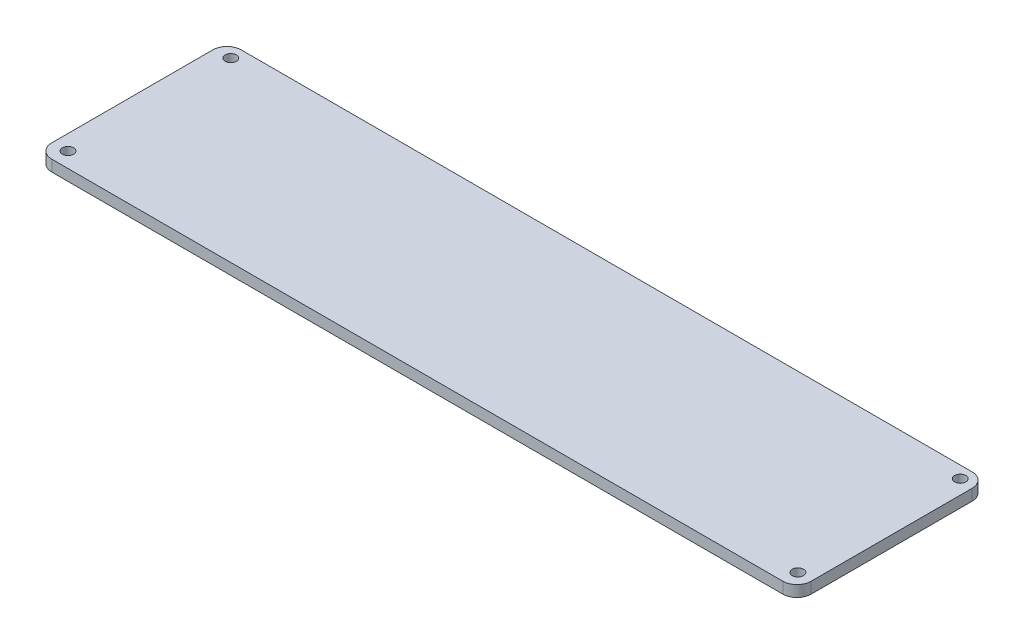
from build123d import *

# Parameters (mm, degrees)
SKETCH_1_W      = 203.2
SKETCH_1_H      = 50.673
SKETCH_1_R      = 1.5
EXTRUDE_1_DEPTH = 3
FILLET_1_R      = 3.8


with BuildPart() as part:
    # 草图1 → 凸台-拉伸1 (new body)
    with BuildSketch(Plane(origin=(0, 0, 0), x_dir=(1, 0, 0), z_dir=(0, 1, 0))):
        with Locations((-0.786381305, 0.982976631)):
            Rectangle(SKETCH_1_W, SKETCH_1_H)
        with Locations((97.003618695, -20.289523369)):
            Circle(SKETCH_1_R, mode=Mode.SUBTRACT)
        with Locations((97.003618695, 23.144476631)):
            Circle(SKETCH_1_R, mode=Mode.SUBTRACT)
        with Locations((-98.068381305, 23.017476631)):
            Circle(SKETCH_1_R, mode=Mode.SUBTRACT)
        with Locations((-98.322381305, -20.289523369)):
            Circle(SKETCH_1_R, mode=Mode.SUBTRACT)
    extrude(amount=EXTRUDE_1_DEPTH)

    # 圆角1
    fillet_1_edges = [part.edges().sort_by_distance(p)[0] for p in [
        (-102.386381305, 1.5, 24.353523369),
        (-102.386381305, 1.5, -26.319476631),
        (100.813618695, 1.5, -26.319476631),
        (100.813618695, 1.5, 24.353523369),
    ]]
    fillet(fillet_1_edges, radius=FILLET_1_R)


solid = part.part
